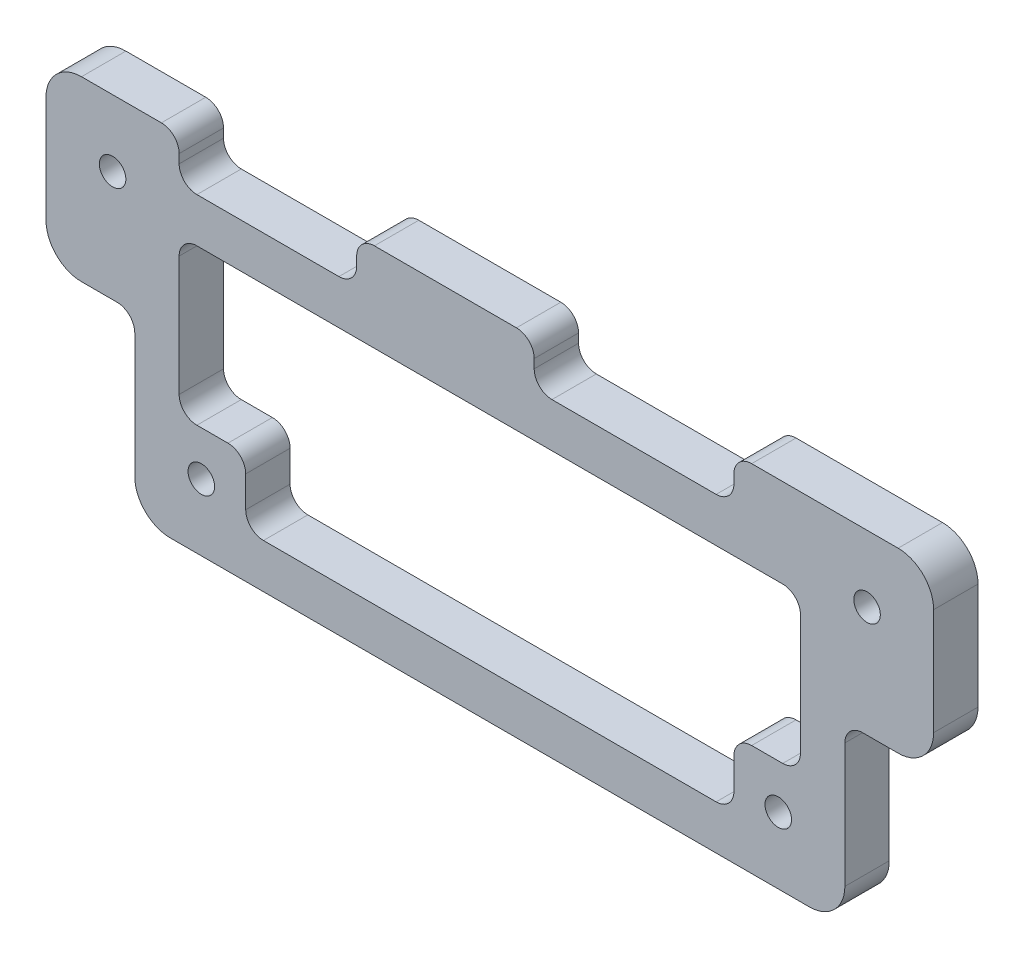
from build123d import *

# Parameters (mm, degrees)
SKETCH1_R           = 1.89865
SKETCH1_R_2         = 1.5875
BOSS_EXTRUDE1_DEPTH = 6.35
FILLET1_R           = 5.08
FILLET2_R           = 2.54
SKETCH2_W           = 25.4
SKETCH2_H           = 6.35
SKETCH2_W_2         = 28.575
CUT_EXTRUDE1_DEPTH  = 8.89
FILLET3_R           = 2.54


with BuildPart() as part:
    # Sketch1 → Boss-Extrude1 (new body)
    with BuildSketch(Plane.XY):
        Polygon((0, 50.8), (0, 25.4), (12.7, 25.4), (12.7, 0), (114.3, 0), (114.3, 25.4), (127, 25.4), (127, 50.8), align=None)
        with Locations((22.225, 9.525)):
            Circle(SKETCH1_R, mode=Mode.SUBTRACT)
        with Locations((52.324, 19.558)):
            Circle(SKETCH1_R_2, mode=Mode.SUBTRACT)
        with Locations((104.775, 9.525)):
            Circle(SKETCH1_R, mode=Mode.SUBTRACT)
        with Locations((52.324, 30.734)):
            Circle(SKETCH1_R_2, mode=Mode.SUBTRACT)
        with Locations((9.525, 41.275)):
            Circle(SKETCH1_R, mode=Mode.SUBTRACT)
        with Locations((23.622, 47.625)):
            Circle(SKETCH1_R_2, mode=Mode.SUBTRACT)
        with Locations((38.1, 47.625)):
            Circle(SKETCH1_R_2, mode=Mode.SUBTRACT)
        with Locations((78.74, 47.625)):
            Circle(SKETCH1_R_2, mode=Mode.SUBTRACT)
        with Locations((89.662, 47.625)):
            Circle(SKETCH1_R_2, mode=Mode.SUBTRACT)
        with Locations((117.475, 41.275)):
            Circle(SKETCH1_R, mode=Mode.SUBTRACT)
    extrude(amount=BOSS_EXTRUDE1_DEPTH)

    # Fillet1
    fillet1_edges = [part.edges().sort_by_distance(p)[0] for p in [
        (114.3, 0, 3.175),
        (12.7, 0, 3.175),
        (0, 25.4, 3.175),
        (0, 50.8, 3.175),
        (127, 50.8, 3.175),
        (127, 25.4, 3.175),
    ]]
    fillet(fillet1_edges, radius=FILLET1_R)

    # Fillet2
    fillet2_edges = [part.edges().sort_by_distance(p)[0] for p in [
        (12.7, 25.4, 3.175),
        (114.3, 25.4, 3.175),
    ]]
    fillet(fillet2_edges, radius=FILLET2_R)

    # Sketch2 → Cut-Extrude1 (cut)
    with BuildSketch(Plane.XY.offset(6.35)):
        with Locations((31.75, 47.625)):
            Rectangle(SKETCH2_W, SKETCH2_H)
        with Locations((84.1375, 47.625)):
            Rectangle(SKETCH2_W_2, SKETCH2_H)
        Polygon((19.05, 38.1), (19.05, 15.875), (28.575, 15.875), (28.575, 6.35), (98.425, 6.35), (98.425, 15.875), (107.95, 15.875), (107.95, 38.1), align=None)
    extrude(amount=-CUT_EXTRUDE1_DEPTH, mode=Mode.SUBTRACT)

    # Fillet3
    fillet3_edges = [part.edges().sort_by_distance(p)[0] for p in [
        (19.05, 50.8, 3.175),
        (44.45, 50.8, 3.175),
        (44.45, 44.45, 3.175),
        (19.05, 44.45, 3.175),
        (69.85, 50.8, 3.175),
        (98.425, 50.8, 3.175),
        (98.425, 44.45, 3.175),
        (69.85, 44.45, 3.175),
        (19.05, 38.1, 3.175),
        (107.95, 38.1, 3.175),
        (107.95, 15.875, 3.175),
        (98.425, 15.875, 3.175),
        (98.425, 6.35, 3.175),
        (28.575, 6.35, 3.175),
        (28.575, 15.875, 3.175),
        (19.05, 15.875, 3.175),
    ]]
    fillet(fillet3_edges, radius=FILLET3_R)


solid = part.part
